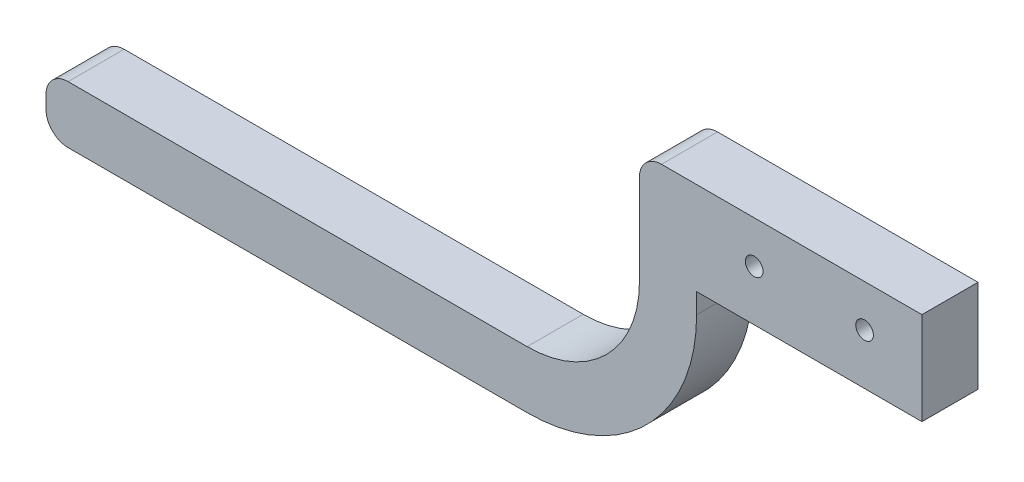
from build123d import *

# Parameters (mm, degrees)
BOSS_EXTRUDE1_DEPTH = 12.7
FILLET1_R           = 5
SKETCH2_R           = 2
CUT_EXTRUDE1_DEPTH  = 13.7


with BuildPart() as part:
    # Sketch1 → Boss-Extrude1 (new body)
    with BuildSketch(Plane.XY):
        with BuildLine():
            Line((0, 0), (-64, 0))
            Line((-64, 0), (-64, -25.552169744))
            ThreePointArc((-64, -25.552169744), (-71.453496915, -43.546503085), (-89.447830256, -51))
            Line((-89.447830256, -51), (-198.447830256, -51))
            Line((-198.447830256, -51), (-198.447830256, -63.95586098))
            Line((-198.447830256, -63.95586098), (-89.447830256, -63.95586098))
            ThreePointArc((-89.447830256, -63.95586098), (-62.29231976, -52.70768024), (-51.04413902, -25.552169744))
            Line((-51.04413902, -25.552169744), (-51.04413902, -21))
            Line((-51.04413902, -21), (0, -21))
            Line((0, -21), (0, 0))
        make_face()
    extrude(amount=BOSS_EXTRUDE1_DEPTH)

    # Fillet1
    fillet1_edges = [part.edges().sort_by_distance(p)[0] for p in [
        (-198.447830256, -63.95586098, 6.35),
        (-198.447830256, -51, 6.35),
        (-64, 0, 6.35),
    ]]
    fillet(fillet1_edges, radius=FILLET1_R)

    # Sketch2 → Cut-Extrude1 (cut, through all)
    with BuildSketch(Plane.XY.offset(12.7)):
        with Locations((-13, -9.531609903)):
            Circle(SKETCH2_R)
        with Locations((-38, -9.531609903)):
            Circle(SKETCH2_R)
    extrude(amount=-CUT_EXTRUDE1_DEPTH, mode=Mode.SUBTRACT)


solid = part.part
